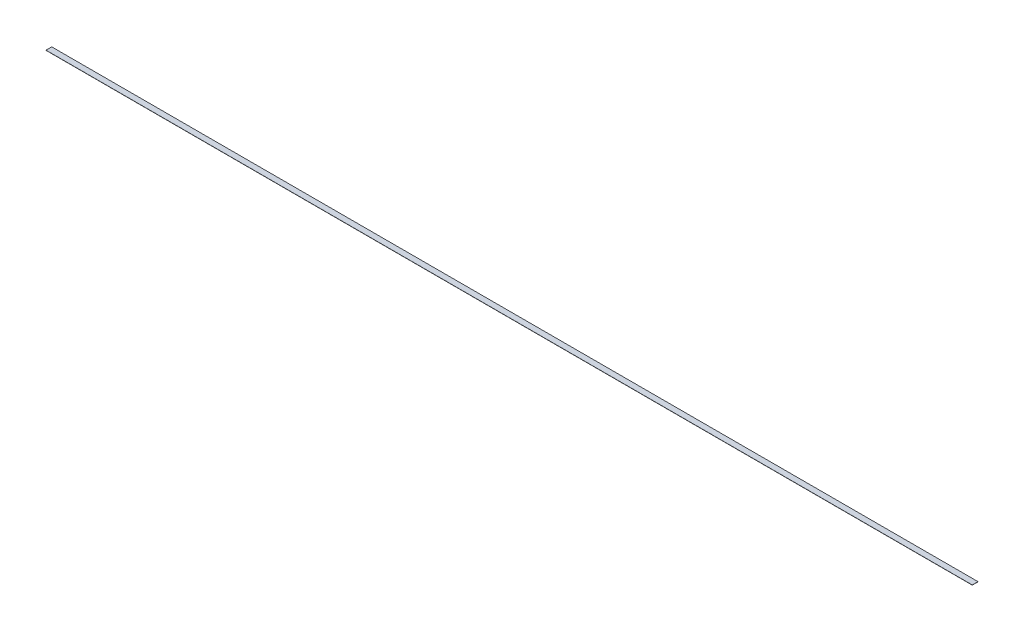
from build123d import *

# Parameters (mm, degrees)
SKETCH1_W           = 8204.2
SKETCH1_H           = 50.8
BOSS_EXTRUDE1_DEPTH = 1.5875


with BuildPart() as part:
    # Sketch1 → Boss-Extrude1 (new body)
    with BuildSketch(Plane(origin=(0, 0, 0), x_dir=(1, 0, 0), z_dir=(0, 1, 0))):
        with Locations((4102.1, 25.4)):
            Rectangle(SKETCH1_W, SKETCH1_H)
    extrude(amount=BOSS_EXTRUDE1_DEPTH)


solid = part.part
